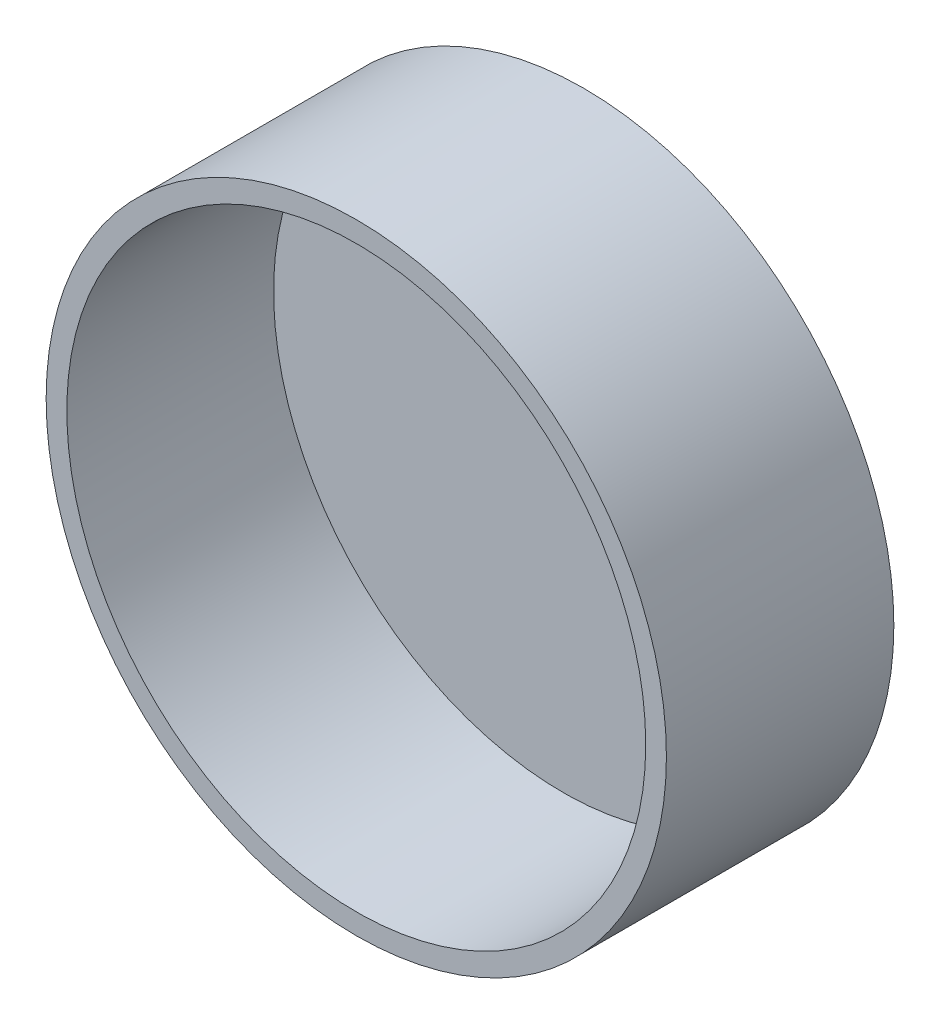
from build123d import *

# Parameters (mm, degrees)
SKETCH2_R           = 15
BOSS_EXTRUDE1_DEPTH = 11
SKETCH4_R           = 14
CUT_EXTRUDE1_DEPTH  = 10


with BuildPart() as part:
    # Sketch2 → Boss-Extrude1 (new body)
    with BuildSketch(Plane.XY):
        Circle(SKETCH2_R)
    extrude(amount=BOSS_EXTRUDE1_DEPTH)

    # Sketch4 → Cut-Extrude1 (cut)
    with BuildSketch(Plane.XY.offset(11)):
        Circle(SKETCH4_R)
    extrude(amount=-CUT_EXTRUDE1_DEPTH, mode=Mode.SUBTRACT)


solid = part.part
